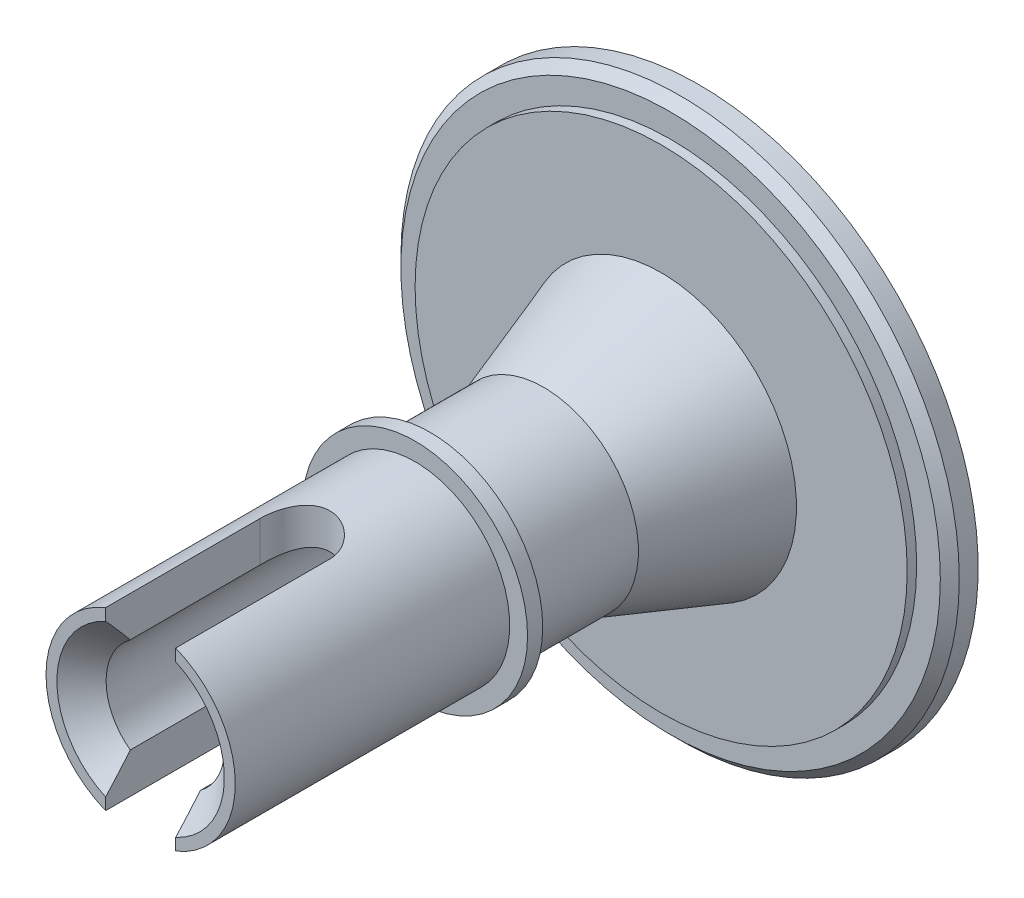
from build123d import *

# Parameters (mm, degrees)
FASE1_SIZE                           = 0.5
FASE2_SIZE                           = 1.3
SCHNITT_LINEAR_AUSTRAGEN1_DEPTH      = 15.75
SCHNITT_LINEAR_AUSTRAGEN1_DEPTH_BACK = 15.75
SKIZZE4_OUTSIDE_W                    = 41.778
SKIZZE4_OUTSIDE_H                    = 41.778
SKIZZE4_OUTSIDE_W_2                  = 20
SKIZZE4_OUTSIDE_H_2                  = 17
SCHNITT_LINEAR_AUSTRAGEN2_DEPTH      = 0.5


with BuildPart() as part:
    # Skizze2 → Rotation1 (revolve)
    with BuildSketch(Plane(origin=(0, 0, 0), x_dir=(0, 0, -1), z_dir=(1, 0, 0))):
        Polygon((0, 14.75), (-1.5, 14.75), (-1.5, 13), (-2, 13), (-2, 7.15), (-8.2, 5), (-14.2, 5), (-14.2, 5.942548531), (-15, 5.942548531), (-15, 5), (-29.5, 5), (-29.5, 3.125), (-4.5, 3.125), (-4.5, 1.45), (-2, 1.45), (-2, 3.9), (0, 3.9), (0, 7.5), (0.5, 7.5), (0.5, 9.5), (0, 9.5), (0, 12.65), (-0.8, 12.65), (-0.8, 14.15), (0, 14.15), align=None)
    revolve(axis=Axis((0, 0, -10.606367747), (0, 0, 1)))

    # Fase1
    fase1_edges = [part.edges().sort_by_distance(p)[0] for p in [
        (0, -14.75, 1.5),
    ]]
    chamfer(fase1_edges, length=FASE1_SIZE)

    # Fase2
    fase2_edges = [part.edges().sort_by_distance(p)[0] for p in [
        (0, -3.125, 29.5),
    ]]
    chamfer(fase2_edges, length=FASE2_SIZE)

    # Skizze3 → Schnitt-Linear austragen1 (cut, two sides)
    with BuildSketch(Plane(origin=(0, 0, 0), x_dir=(1, 0, 0), z_dir=(0, 1, 0))) as schnitt_linear_austragen1_sk:
        with BuildLine():
            Line((1.85, -21.35), (1.85, -29.5))
            ThreePointArc((1.85, -29.5), (0, -31.35), (-1.85, -29.5))
            Line((-1.85, -29.5), (-1.85, -21.35))
            ThreePointArc((-1.85, -21.35), (0, -19.5), (1.85, -21.35))
        make_face()
    extrude(amount=SCHNITT_LINEAR_AUSTRAGEN1_DEPTH, mode=Mode.SUBTRACT)
    extrude(schnitt_linear_austragen1_sk.sketch, amount=-SCHNITT_LINEAR_AUSTRAGEN1_DEPTH_BACK, mode=Mode.SUBTRACT)

    # Skizze4 outside → Schnitt-Linear austragen2 (cut)
    with BuildSketch(Plane(origin=(0, 0, -0.5), x_dir=(-1, 0, 0), z_dir=(0, 0, -1))):
        Rectangle(SKIZZE4_OUTSIDE_W, SKIZZE4_OUTSIDE_H)
        Rectangle(SKIZZE4_OUTSIDE_W_2, SKIZZE4_OUTSIDE_H_2, mode=Mode.SUBTRACT)
    extrude(amount=-SCHNITT_LINEAR_AUSTRAGEN2_DEPTH, mode=Mode.SUBTRACT)


solid = part.part
